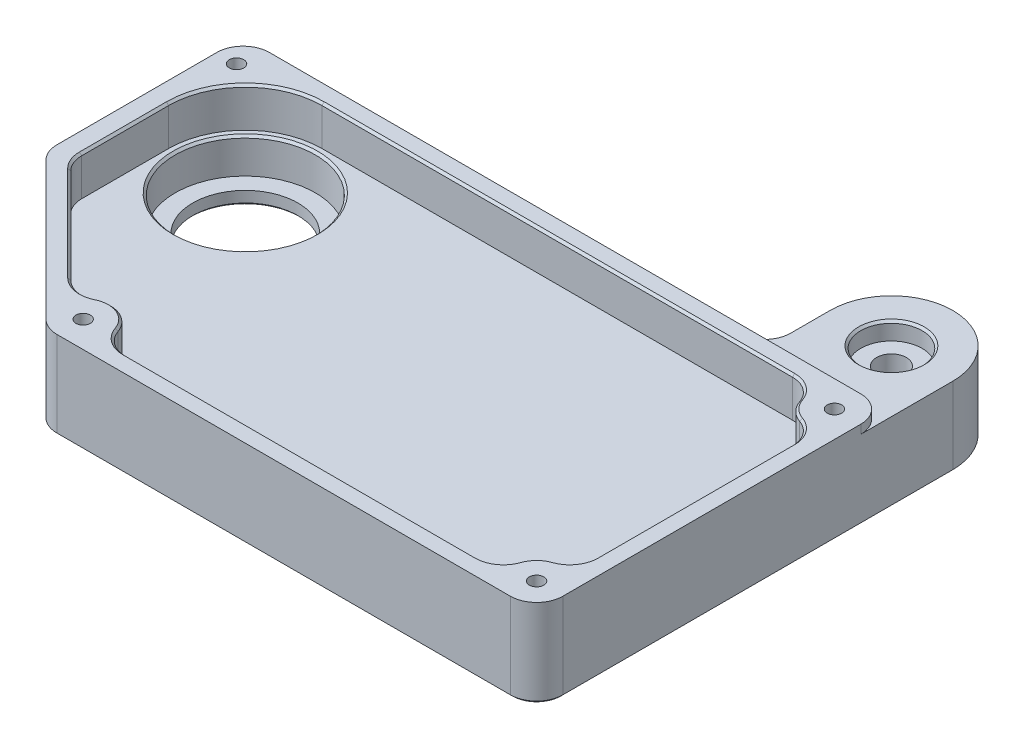
from build123d import *

# Parameters (mm, degrees)
SKETCH2_R                   = 12
BOSS_EXTRUDE1_DEPTH         = 20
FILLET1_R                   = 6
TAP_DRILL_FOR_M4_TAP1_D     = 3.3
TAP_DRILL_FOR_M4_TAP1_DEPTH = 13
TAP_DRILL_FOR_M4_TAP1_TIP   = 0.991420021
CUT_EXTRUDE4_DEPTH          = 9
FILLET2_R                   = 6
SKETCH8_R                   = 16
CUT_EXTRUDE5_DEPTH          = 8
TAP_DRILL_FOR_M8_TAP1_D     = 6.8
CUT_EXTRUDE6_DEPTH          = 2
SKETCH13_R                  = 7
CUT_EXTRUDE7_DEPTH          = 4
CHAMFER1_SIZE               = 0.5
CHAMFER2_SIZE               = 0.5


with BuildPart() as part:
    # Sketch2 → Boss-Extrude1 (new body)
    with BuildSketch(Plane(origin=(0, 0, 0), x_dir=(1, 0, 0), z_dir=(0, 1, 0))):
        with BuildLine():
            Line((-57, 40), (62, 40))
            Line((62, 40), (62, 55))
            ThreePointArc((62, 55), (76, 69), (90, 55))
            Line((90, 55), (90, -40))
            Line((90, -40), (-22, -40))
            Line((-22, -40), (-57, -5))
            Line((-57, -5), (-57, 40))
        make_face()
        with Locations((-35, 18.5)):
            Circle(SKETCH2_R, mode=Mode.SUBTRACT)
    extrude(amount=BOSS_EXTRUDE1_DEPTH)

    # Fillet1
    fillet1_edges = [part.edges().sort_by_distance(p)[0] for p in [
        (90, 10, 40),
        (-22, 10, 40),
        (-57, 10, 5),
        (-57, 10, -40),
        (62, 10, -40),
    ]]
    fillet(fillet1_edges, radius=FILLET1_R)

    # Tap Drill for M4 Tap1
    with Locations(Plane(origin=(0, 20, 0), x_dir=(1, 0, 0), z_dir=(0, 1, 0))):
        with Locations((-19.514718626, -34), (-52.5, 34), (84, -34), (84, 34)):
            Hole(TAP_DRILL_FOR_M4_TAP1_D / 2, depth=TAP_DRILL_FOR_M4_TAP1_DEPTH)
            with Locations((0, 0, -(TAP_DRILL_FOR_M4_TAP1_DEPTH + TAP_DRILL_FOR_M4_TAP1_TIP / 2))):  # 118° drill point
                Cone(0, TAP_DRILL_FOR_M4_TAP1_D / 2, TAP_DRILL_FOR_M4_TAP1_TIP, mode=Mode.SUBTRACT)

    # Sketch7 → Cut-Extrude4 (cut)
    with BuildSketch(Plane(origin=(0, 20, 0), x_dir=(1, 0, 0), z_dir=(0, 1, 0))):
        with BuildLine():
            Line((-52.5, 18.5), (-52.5, -1.357864376))
            ThreePointArc((-52.5, -1.357864376), (-52.043277195, -3.65396497), (-50.742640687, -5.600505063))
            Line((-50.742640687, -5.600505063), (-25.115965744, -31.227180006))
            ThreePointArc((-25.115965744, -31.227180006), (-17.122947173, -28.225752922), (-13.593358985, -36))
            Line((-13.593358985, -36), (78.078640359, -36))
            ThreePointArc((78.078640359, -36), (79.580582618, -29.580582618), (86, -28.078640359))
            Line((86, -28.078640359), (86, 28.078640359))
            ThreePointArc((86, 28.078640359), (79.580582618, 29.580582618), (78.078640359, 36))
            Line((78.078640359, 36), (-35, 36))
            ThreePointArc((-35, 36), (-47.374368671, 30.874368671), (-52.5, 18.5))
        make_face()
    extrude(amount=-CUT_EXTRUDE4_DEPTH, mode=Mode.SUBTRACT)

    # Fillet2
    fillet2_edges = [part.edges().sort_by_distance(p)[0] for p in [
        (86, 15.5, 28.078640359),
        (78.078640359, 15.5, 36),
        (-13.593358985, 15.5, 36),
        (-25.115965744, 15.5, 31.227180006),
        (78.078640359, 15.5, -36),
        (86, 15.5, -28.078640359),
    ]]
    fillet(fillet2_edges, radius=FILLET2_R)

    # Sketch8 → Cut-Extrude5 (cut)
    with BuildSketch(Plane(origin=(0, 11, 0), x_dir=(1, 0, 0), z_dir=(0, 1, 0))):
        with Locations((-35, 18.5)):
            Circle(SKETCH8_R)
    extrude(amount=-CUT_EXTRUDE5_DEPTH, mode=Mode.SUBTRACT)

    # Tap Drill for M8 Tap1 (through all)
    with Locations(Plane(origin=(0, 20, 0), x_dir=(1, 0, 0), z_dir=(0, 1, 0))):
        with Locations((76, 55)):
            Hole(TAP_DRILL_FOR_M8_TAP1_D / 2)

    # Sketch12 → Cut-Extrude6 (cut)
    with BuildSketch(Plane(origin=(0, 20, 0), x_dir=(1, 0, 0), z_dir=(0, 1, 0))):
        with BuildLine():
            Line((84, 40), (50.858800106, 40))
            Line((50.858800106, 40), (50.858800106, 55))
            ThreePointArc((50.858800106, 55), (76, 80.141199894), (101.141199894, 55))
            Line((101.141199894, 55), (101.141199894, 34))
            Line((101.141199894, 34), (90, 34))
            ThreePointArc((90, 34), (88.242640687, 38.242640687), (84, 40))
        make_face()
    extrude(amount=-CUT_EXTRUDE6_DEPTH, mode=Mode.SUBTRACT)

    # Sketch13 → Cut-Extrude7 (cut)
    with BuildSketch(Plane(origin=(0, 18, 0), x_dir=(1, 0, 0), z_dir=(0, 1, 0))):
        with Locations((76, 55)):
            Circle(SKETCH13_R)
    extrude(amount=-CUT_EXTRUDE7_DEPTH, mode=Mode.SUBTRACT)

    # Chamfer1
    chamfer1_edges = [part.edges().sort_by_distance(p)[0] for p in [
        (62, 0, -50.5),
        (76, 0, -69),
        (90, 0, -10.5),
        (-47, 0, -18.5),
        (79.4, 0, -55),
        (32.242640687, 0, 40),
        (-39.5, 0, 22.5),
        (-57, 0, -15.742640687),
        (2.5, 0, -40),
        (88.242640687, 0, 38.242640687),
        (-55.242640687, 0, -38.242640687),
        (-56.543277195, 0, 4.81081922),
        (-21.81081922, 0, 39.543277195),
        (60.242640687, 0, -41.757359313),
    ]]
    chamfer(chamfer1_edges, length=CHAMFER1_SIZE)

    # Chamfer2
    chamfer2_edges = [part.edges().sort_by_distance(p)[0] for p in [
        (-17.122947173, 20, 28.225752922),
        (32.242640687, 20, 36),
        (79.580582618, 20, -29.580582618),
        (86, 20, 0),
        (18.710731912, 20, -36),
        (79.580582618, 20, 29.580582618),
        (-25.866850849, 20, 28.901520169),
        (-11.417913194, 20, 34.886466108),
        (84.886466108, 20, -25.903194568),
        (75.903194568, 20, -34.886466108),
        (84.886466108, 20, 25.903194568),
        (75.903194568, 20, 34.886466108),
        (-51, 11, -18.5),
        (69, 18, -55),
        (-47.374368671, 20, -30.874368671),
        (-52.5, 20, -8.571067812),
        (-52.043277195, 20, 3.65396497),
        (-39.929417161, 20, 16.413728589),
    ]]
    chamfer(chamfer2_edges, length=CHAMFER2_SIZE)


solid = part.part
